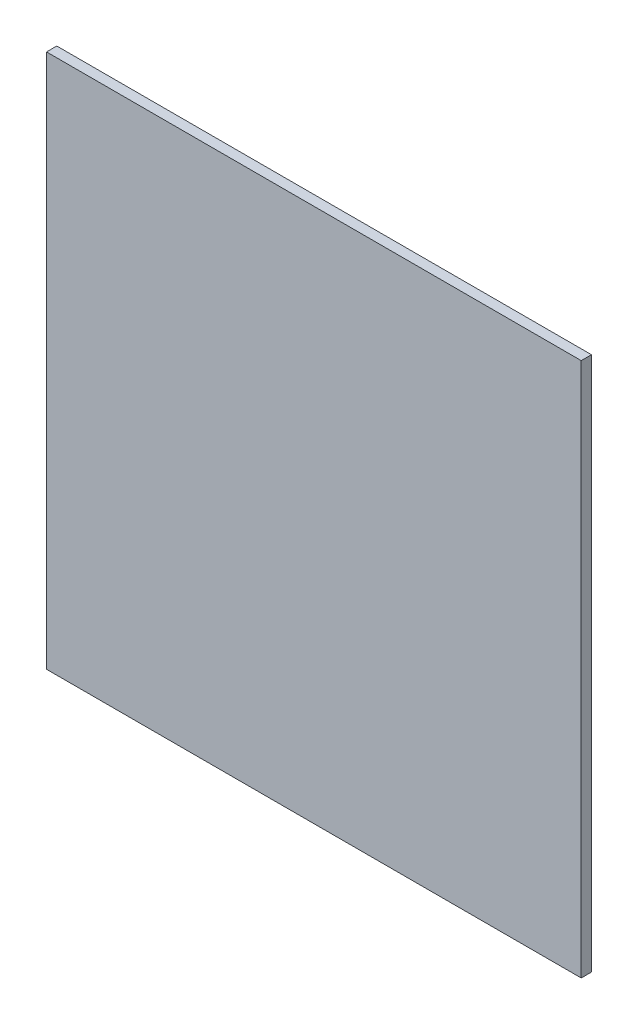
from build123d import *

# Parameters (mm, degrees)
SZKIC1_W                    = 470
SZKIC1_H                    = 470
DODANIE_WYCI_GNI_CIE1_DEPTH = 9


with BuildPart() as part:
    # Szkic1 → Dodanie-wyciągnięcie1 (new body)
    with BuildSketch(Plane.XY):
        with Locations((235, 235)):
            Rectangle(SZKIC1_W, SZKIC1_H)
    extrude(amount=-DODANIE_WYCI_GNI_CIE1_DEPTH)


solid = part.part
